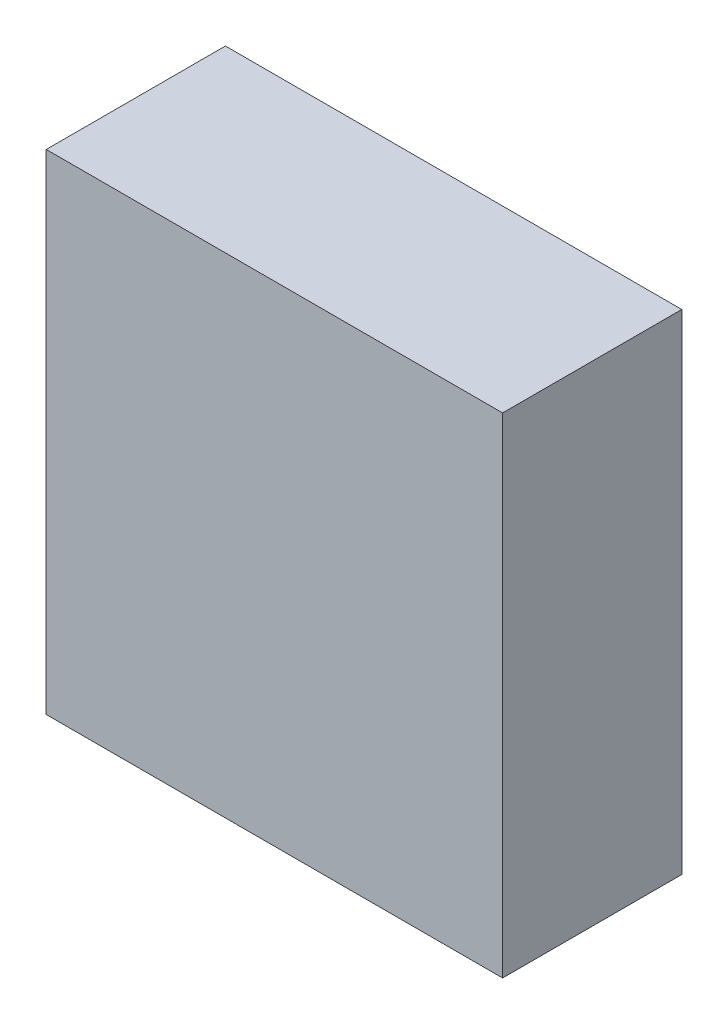
from build123d import *

# Parameters (mm, degrees)
SKETCH_1_W      = 87.4
SKETCH_1_H      = 81.5
EXTRUDE_1_DEPTH = 32


with BuildPart() as part:
    # ｽｹｯﾁ1 → ﾎﾞｽ - 押し出し1 (new body)
    with BuildSketch(Plane(origin=(0, 0, 0), x_dir=(0, 1, 0), z_dir=(0, 0, 1))):
        with Locations((43.7, 40.75)):
            Rectangle(SKETCH_1_W, SKETCH_1_H)
    extrude(amount=EXTRUDE_1_DEPTH)


solid = part.part
